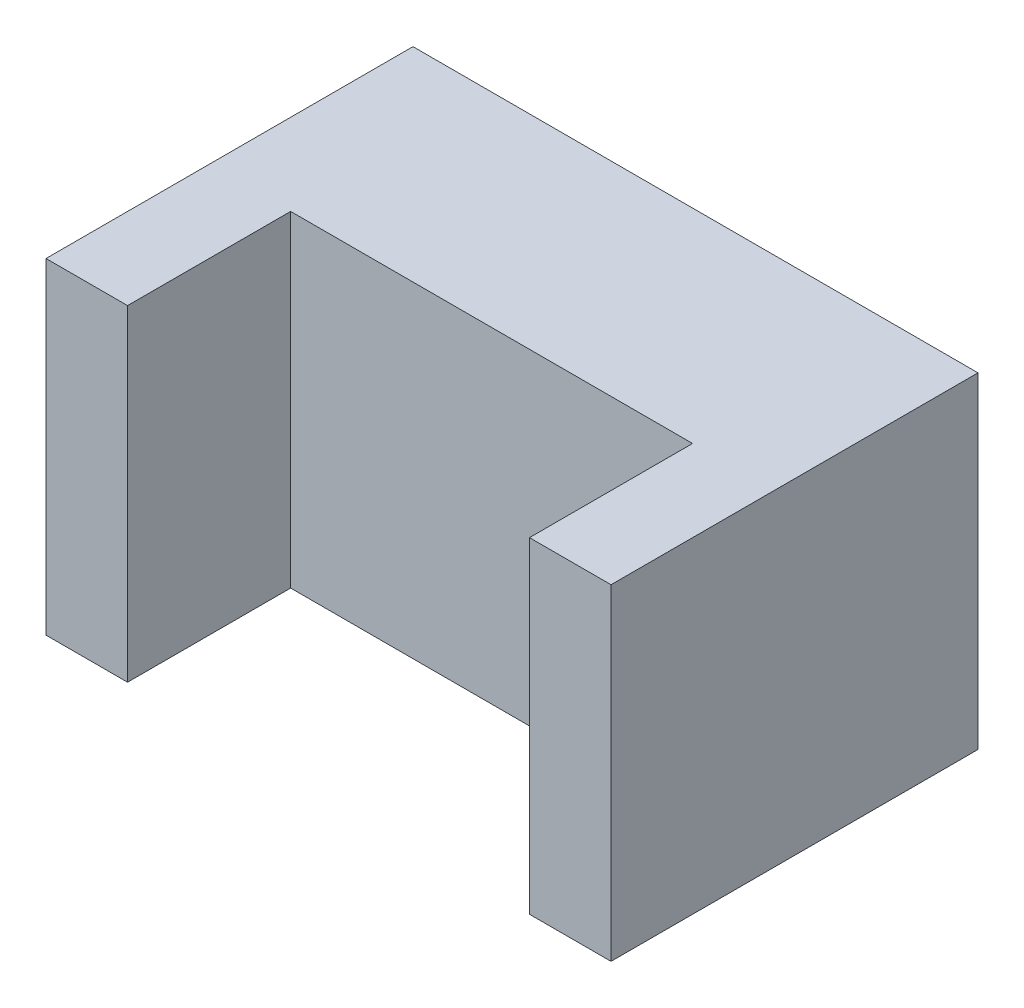
from build123d import *

# Parameters (mm, degrees)
BOSS_EXTRUDE1_DEPTH = 4


with BuildPart() as part:
    # Sketch2 → Boss-Extrude1 (new body)
    with BuildSketch(Plane(origin=(0, 0, 0), x_dir=(1, 0, 0), z_dir=(0, 1, 0))):
        Polygon((-2.642857143, 0), (-2.642857143, 4.5), (4.285714286, 4.5), (4.285714286, 0), (3.285714286, 0), (3.285714286, 2), (-1.642857143, 2), (-1.642857143, 0), align=None)
    extrude(amount=BOSS_EXTRUDE1_DEPTH)


solid = part.part
